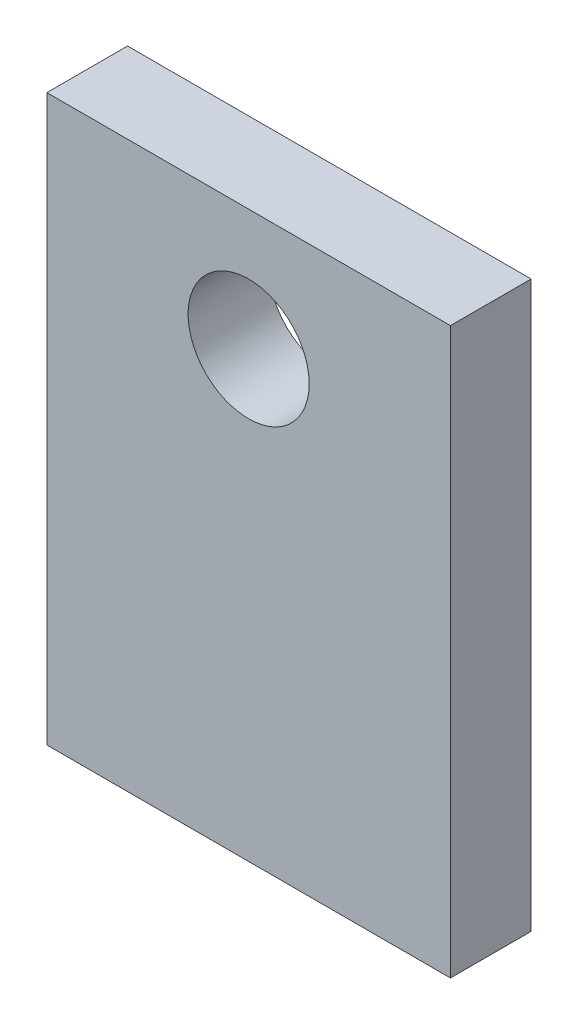
from build123d import *

# Parameters (mm, degrees)
SKETCH1_W          = 127
SKETCH1_H          = 177.8
SKETCH1_R          = 19.05
BASE_EXTRUDE_DEPTH = 25.4


with BuildPart() as part:
    # Sketch1 → Base-Extrude (new body)
    with BuildSketch(Plane.XY):
        with Locations((63.5, 88.9)):
            Rectangle(SKETCH1_W, SKETCH1_H)
        with Locations((63.5, 139.7)):
            Circle(SKETCH1_R, mode=Mode.SUBTRACT)
    extrude(amount=BASE_EXTRUDE_DEPTH)


solid = part.part
